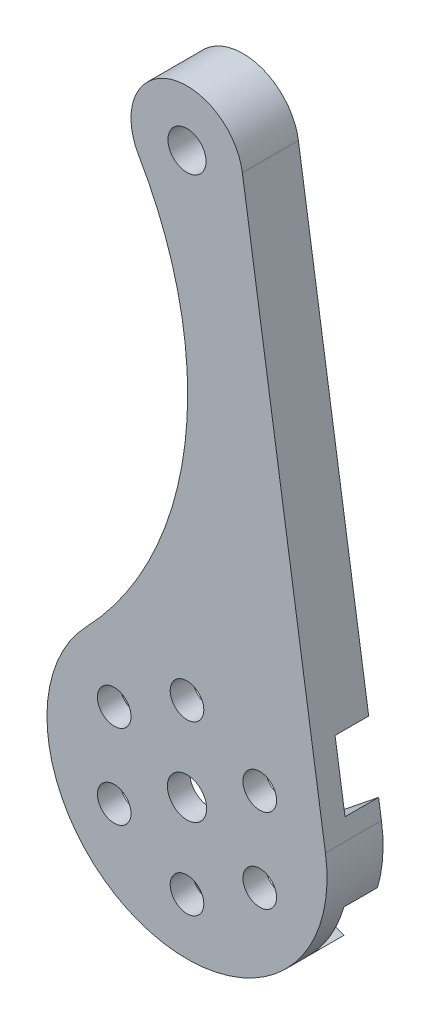
from build123d import *

# Parameters (mm, degrees)
SKETCH_1_R      = 1.7
SKETCH_1_R_2    = 1.75
SKETCH_1_R_3    = 1.5
EXTRUDE_1_DEPTH = 2
SKETCH_2_R      = 1.7
EXTRUDE_2_DEPTH = 3


with BuildPart() as part:
    # 草图1 → 凸台-拉伸1 (new body)
    with BuildSketch(Plane.XY):
        with BuildLine():
            Line((4.943429983, 50.75), (12.358574958, 1.875))
            ThreePointArc((12.358574958, 1.875), (-3.784680756, -11.913277953), (-9.010584258, 8.663681166))
            ThreePointArc((-9.010584258, 8.663681166), (-0.173058011, 27.293788413), (-4.325142467, 47.491386311))
            ThreePointArc((-4.325142467, 47.491386311), (-1.658375909, 54.716968236), (4.943429983, 50.75))
        make_face()
        with Locations((0, 50)):
            Circle(SKETCH_1_R, mode=Mode.SUBTRACT)
        Circle(SKETCH_1_R_2, mode=Mode.SUBTRACT)
        with Locations((-6.495190528, -3.75)):
            Circle(SKETCH_1_R_3, mode=Mode.SUBTRACT)
        with Locations((-6.495190528, 3.75)):
            Circle(SKETCH_1_R_3, mode=Mode.SUBTRACT)
        with Locations((0, 7.5)):
            Circle(SKETCH_1_R_3, mode=Mode.SUBTRACT)
        with Locations((6.495190528, 3.75)):
            Circle(SKETCH_1_R_3, mode=Mode.SUBTRACT)
        with Locations((6.495190528, -3.75)):
            Circle(SKETCH_1_R_3, mode=Mode.SUBTRACT)
        with Locations((0, -7.5)):
            Circle(SKETCH_1_R_3, mode=Mode.SUBTRACT)
    extrude(amount=EXTRUDE_1_DEPTH)

    # 草图2 → 凸台-拉伸2 (add)
    with BuildSketch(Plane(origin=(0, 0, 0), x_dir=(-1, 0, 0), z_dir=(0, 0, -1))):
        with BuildLine():
            Line((-12.104606684, 3.548965842), (-12.358574958, 1.875))
            ThreePointArc((-12.358574958, 1.875), (-12.473254326, -0.817267717), (-12.008260108, -3.471554287))
            Line((-12.008260108, -3.471554287), (-7.687556684, 0))
            Line((-7.687556684, 0), (-12.104606684, 3.548965842))
        make_face()
        with BuildLine():
            Line((-4.943429983, 50.75), (-11.218143605, 9.391856725))
            ThreePointArc((-11.218143605, 9.391856725), (-10.811437733, 9.330472298), (-10.418112816, 9.210167583))
            Line((-10.418112816, 9.210167583), (-3.843778342, 6.657619381))
            Line((-3.843778342, 6.657619381), (-2.767182691, 13.62743415))
            ThreePointArc((-2.767182691, 13.62743415), (0, 16), (2.767182691, 13.62743415))
            Line((2.767182691, 13.62743415), (3.843778342, 6.657619381))
            Line((3.843778342, 6.657619381), (9.010584258, 8.663681166))
            ThreePointArc((9.010584258, 8.663681166), (0.173058011, 27.293788413), (4.325142467, 47.491386311))
            ThreePointArc((4.325142467, 47.491386311), (1.658375909, 54.716968236), (-4.943429983, 50.75))
        make_face()
        with Locations((0, 50)):
            Circle(SKETCH_2_R, mode=Mode.SUBTRACT)
        with BuildLine():
            Line((7.687556684, 0), (12.008260108, 3.471554287))
            ThreePointArc((12.008260108, 3.471554287), (12.5, 0), (12.008260108, -3.471554287))
            Line((12.008260108, -3.471554287), (7.687556684, 0))
        make_face()
        with BuildLine():
            Line((3.843778342, -6.657619381), (9.010584258, -8.663681166))
            ThreePointArc((9.010584258, -8.663681166), (6.25, -10.825317547), (2.997675851, -12.135235453))
            Line((2.997675851, -12.135235453), (3.843778342, -6.657619381))
        make_face()
        with BuildLine():
            Line((-3.843778342, -6.657619381), (-2.997675851, -12.135235453))
            ThreePointArc((-2.997675851, -12.135235453), (-6.25, -10.825317547), (-9.010584258, -8.663681166))
            Line((-9.010584258, -8.663681166), (-3.843778342, -6.657619381))
        make_face()
    extrude(amount=EXTRUDE_2_DEPTH)


solid = part.part
